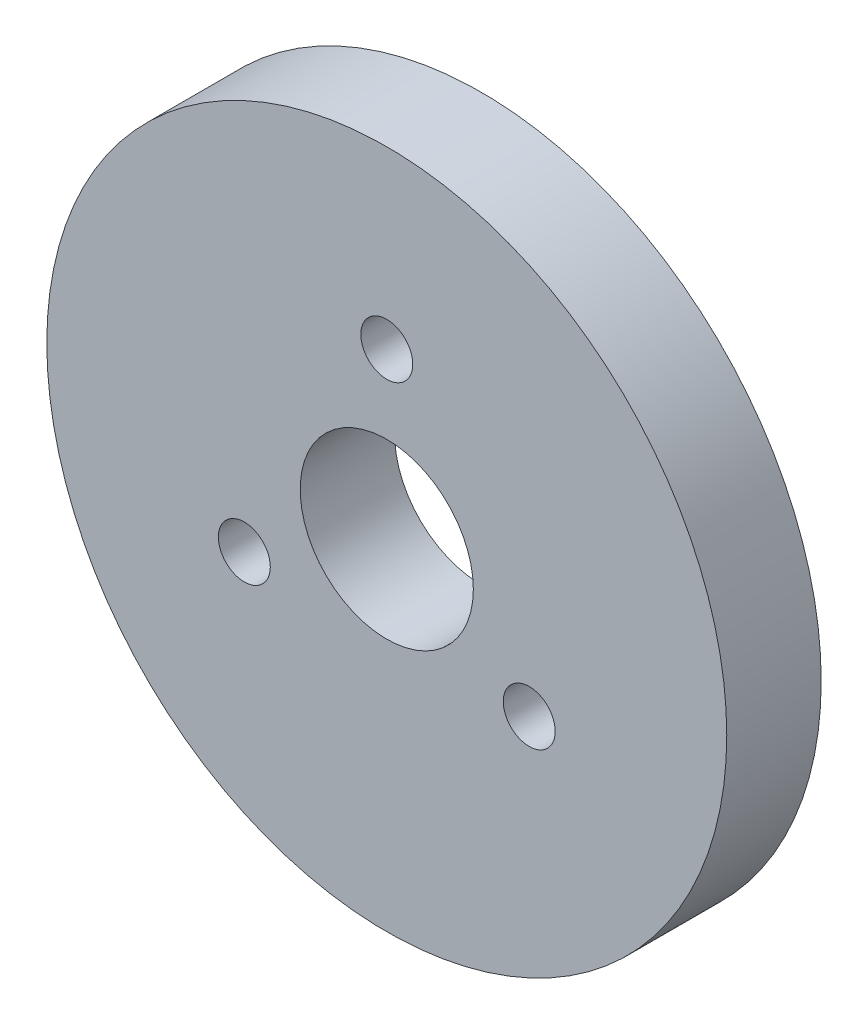
from build123d import *

# Parameters (mm, degrees)
SKETCH1_R           = 21.6
SKETCH1_R_2         = 5.5
BOSS_EXTRUDE1_DEPTH = 6
SKETCH2_R           = 1.65
CUT_EXTRUDE1_DEPTH  = 7


with BuildPart() as part:
    # Sketch1 → Boss-Extrude1 (new body)
    with BuildSketch(Plane.XY):
        Circle(SKETCH1_R)
        Circle(SKETCH1_R_2, mode=Mode.SUBTRACT)
    extrude(amount=BOSS_EXTRUDE1_DEPTH)

    # Sketch2 → Cut-Extrude1 (cut, through all)
    with BuildSketch(Plane.XY.offset(6)):
        with Locations((0, 10.45)):
            Circle(SKETCH2_R)
        with Locations((9.04996547, -5.225)):
            Circle(SKETCH2_R)
        with Locations((-9.04996547, -5.225)):
            Circle(SKETCH2_R)
    extrude(amount=-CUT_EXTRUDE1_DEPTH, mode=Mode.SUBTRACT)


solid = part.part
